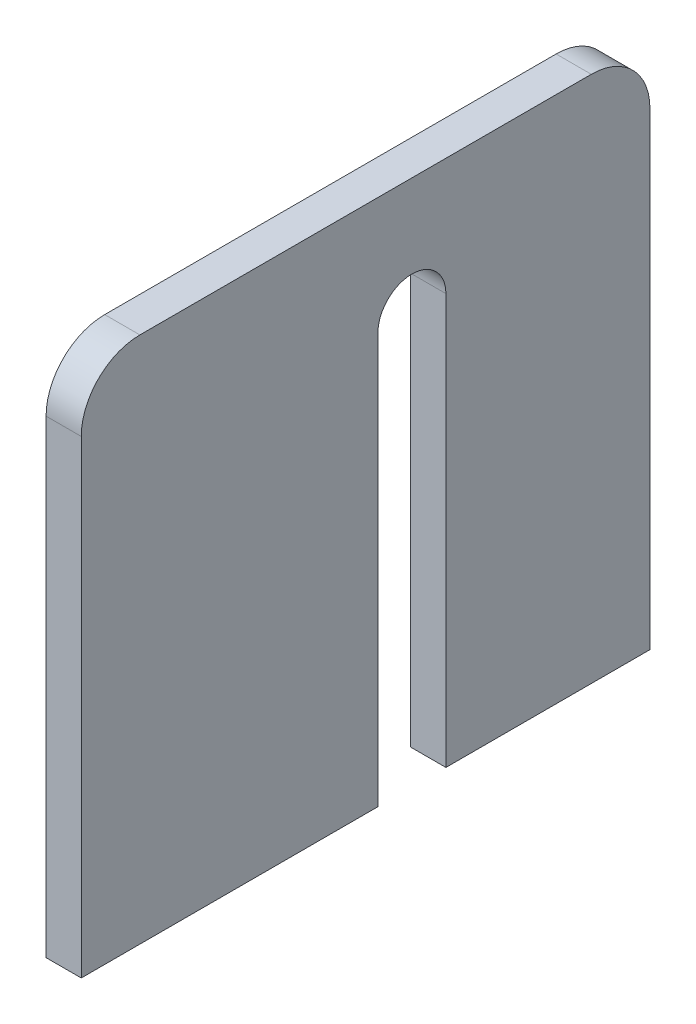
from build123d import *

# Parameters (mm, degrees)
SKETCH1_W           = 48.5
SKETCH1_H           = 45
BOSS_EXTRUDE1_DEPTH = 3
CUT_EXTRUDE1_DEPTH  = 4
FILLET1_R           = 5


with BuildPart() as part:
    # Sketch1 → Boss-Extrude1 (new body)
    with BuildSketch(Plane(origin=(0, 0, 0), x_dir=(0, 0, -1), z_dir=(1, 0, 0))):
        with Locations((24.25, 22.5)):
            Rectangle(SKETCH1_W, SKETCH1_H)
    extrude(amount=BOSS_EXTRUDE1_DEPTH)

    # Sketch2 → Cut-Extrude1 (cut, through all)
    with BuildSketch(Plane(origin=(3, 0, 0), x_dir=(0, 0, -1), z_dir=(1, 0, 0))):
        with BuildLine():
            Line((25.3, 35), (25.3, 0))
            Line((25.3, 0), (31.1, 0))
            Line((31.1, 0), (31.1, 35))
            ThreePointArc((31.1, 35), (28.2, 37.9), (25.3, 35))
        make_face()
    extrude(amount=-CUT_EXTRUDE1_DEPTH, mode=Mode.SUBTRACT)

    # Fillet1
    fillet1_edges = [part.edges().sort_by_distance(p)[0] for p in [
        (1.5, 45, 0),
        (1.5, 45, -48.5),
    ]]
    fillet(fillet1_edges, radius=FILLET1_R)


solid = part.part
